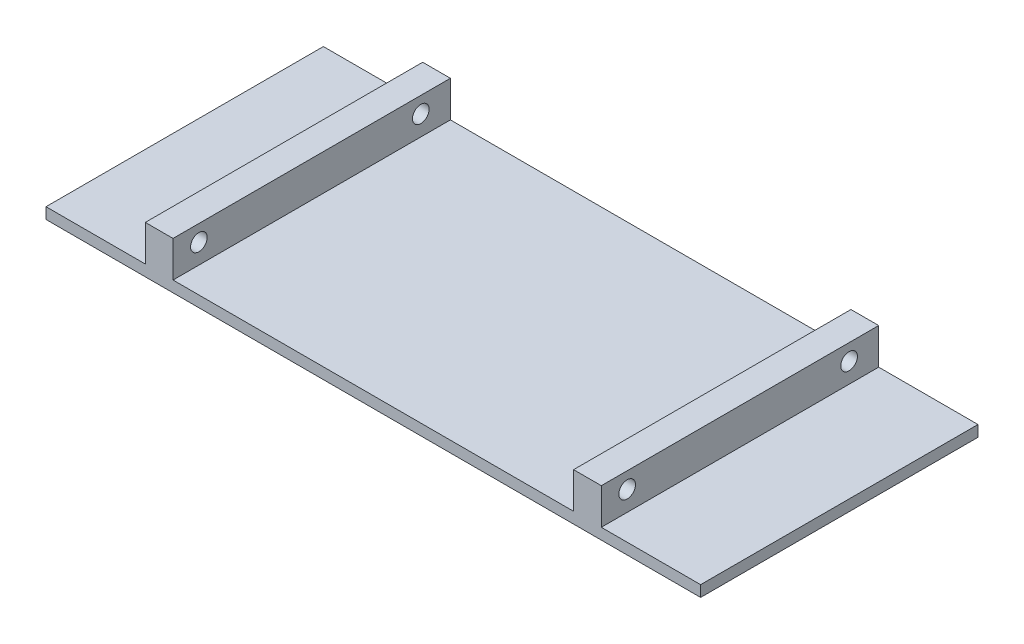
from build123d import *

# Parameters (mm, degrees)
SKETCH1_W           = 118
SKETCH1_H           = 50
BOSS_EXTRUDE1_DEPTH = 2
SKETCH2_W           = 5
SKETCH2_H           = 50
BOSS_EXTRUDE2_DEPTH = 6.5
SKETCH3_R           = 1.5
CUT_EXTRUDE1_DEPTH  = 7


with BuildPart() as part:
    # Sketch1 → Boss-Extrude1 (new body)
    with BuildSketch(Plane(origin=(0, 0, 0), x_dir=(1, 0, 0), z_dir=(0, 1, 0))):
        Rectangle(SKETCH1_W, SKETCH1_H)
    extrude(amount=BOSS_EXTRUDE1_DEPTH)

    # Sketch2 → Boss-Extrude2 (add)
    with BuildSketch(Plane(origin=(0, 2, 0), x_dir=(1, 0, 0), z_dir=(0, 1, 0))):
        with Locations((-38.6, 0)):
            Rectangle(SKETCH2_W, SKETCH2_H)
        with Locations((38.6, 0)):
            Rectangle(SKETCH2_W, SKETCH2_H)
    extrude(amount=BOSS_EXTRUDE2_DEPTH)

    # Sketch3 → Cut-Extrude1 (cut)
    with BuildSketch(Plane(origin=(-36.1, 0, 0), x_dir=(0, 0, -1), z_dir=(1, 0, 0))):
        with Locations((-20.34, 5.589776131)):
            Circle(SKETCH3_R)
        with Locations((19.66, 5.6)):
            Circle(SKETCH3_R)
    cut_extrude1 = extrude(amount=-CUT_EXTRUDE1_DEPTH, mode=Mode.SUBTRACT)

    # Mirror1: Cut-Extrude1 across plane
    add(cut_extrude1.mirror(Plane(origin=(0, 0, 0), x_dir=(0, 0, 1), z_dir=(1, 0, 0))), mode=Mode.SUBTRACT)


solid = part.part
